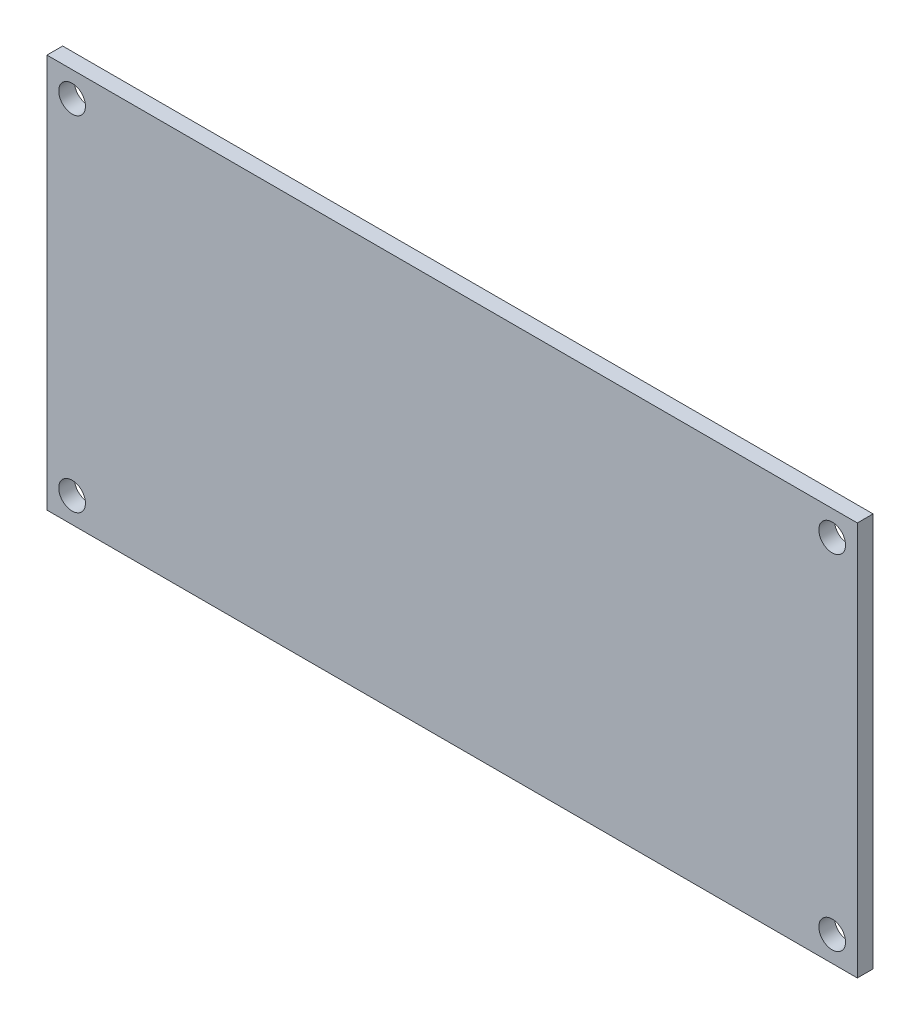
from build123d import *

# Parameters (mm, degrees)
SKETCH1_W                  = 81.876
SKETCH1_H                  = 39.816
BOSS_EXTRUDE1_DEPTH        = 1.5875
F_2_7_2_7_DIAMETER_HOLE1_D = 2.7


with BuildPart() as part:
    # Sketch1 → Boss-Extrude1 (new body)
    with BuildSketch(Plane.XY):
        with Locations((3106.238757164, 1149.455694712)):
            Rectangle(SKETCH1_W, SKETCH1_H)
    extrude(amount=BOSS_EXTRUDE1_DEPTH)

    # Ø2.7 (2.7) Diameter Hole1 (through all)
    with Locations(Plane.XY.offset(1.5875)):
        with Locations((3144.636757164, 1132.087694712), (3067.840757164, 1132.087694712), (3144.636757164, 1166.823694712), (3067.840757164, 1166.823694712)):
            Hole(F_2_7_2_7_DIAMETER_HOLE1_D / 2)


solid = part.part
